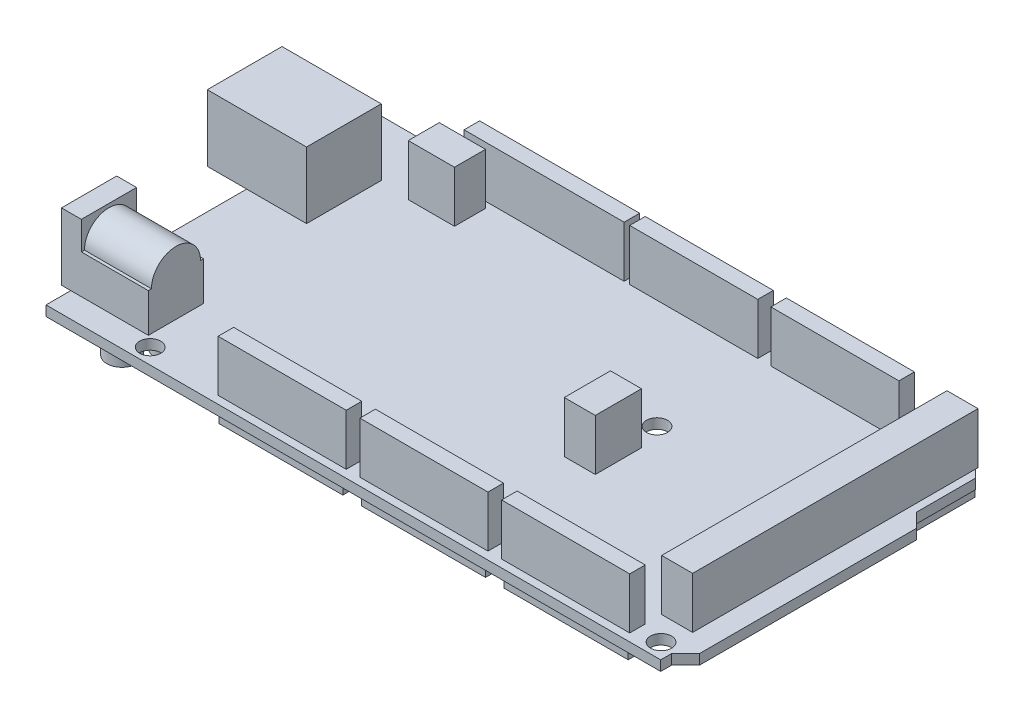
from build123d import *

# Parameters (mm, degrees)
SKETCH2_R           = 1.7
BOSS_EXTRUDE1_DEPTH = 1.625
SKETCH3_W           = 16
SKETCH3_H           = 12.05
BOSS_EXTRUDE2_DEPTH = 10.7
SKETCH4_W           = 14
SKETCH4_H           = 8.9
BOSS_EXTRUDE3_DEPTH = 6.25
SKETCH5_W           = 3.2
SKETCH5_H           = 8.9
BOSS_EXTRUDE4_DEPTH = 4.55
SKETCH6_R           = 3.95
BOSS_EXTRUDE5_DEPTH = 10.8
SKETCH7_R           = 2.43
SKETCH7_R_2         = 1.75
SKETCH7_W           = 4.5
SKETCH7_H           = 45
SKETCH7_W_2         = 20
SKETCH7_H_2         = 2.75
SKETCH7_W_3         = 24.5
SKETCH7_W_4         = 4.25
SKETCH7_H_3         = 7
BOSS_EXTRUDE6_DEPTH = 2.5
SKETCH8_W           = 25.8
SKETCH8_H           = 2.5
SKETCH8_W_2         = 20.65
SKETCH8_W_3         = 5
SKETCH8_H_2         = 46
SKETCH8_H_3         = 7.45
SKETCH8_W_4         = 7.45
SKETCH8_H_4         = 5
BOSS_EXTRUDE7_DEPTH = 8.25


with BuildPart() as part:
    # Sketch2 → Boss-Extrude1 (new body)
    with BuildSketch(Plane(origin=(0, 0, 0), x_dir=(1, 0, 0), z_dir=(0, 1, 0))):
        Polygon((99.1, 0), (99.1, 1.75), (101.35, 4), (101.35, 39), (99.1, 41.25), (99.1, 50.75), (96.45, 53.4), (0, 53.4), (0, 0), align=None)
        with Locations((96.65, 2.5)):
            Circle(SKETCH2_R, mode=Mode.SUBTRACT)
        with Locations((90.65, 50.95)):
            Circle(SKETCH2_R, mode=Mode.SUBTRACT)
        with Locations((15.45, 50.95)):
            Circle(SKETCH2_R, mode=Mode.SUBTRACT)
        with Locations((14.3, 2.5)):
            Circle(SKETCH2_R, mode=Mode.SUBTRACT)
        with Locations((66.2, 32.3)):
            Circle(SKETCH2_R, mode=Mode.SUBTRACT)
        with Locations((66.2, 7.7)):
            Circle(SKETCH2_R, mode=Mode.SUBTRACT)
    extrude(amount=BOSS_EXTRUDE1_DEPTH)

    # Sketch3 → Boss-Extrude2 (add)
    with BuildSketch(Plane(origin=(0, 1.625, 0), x_dir=(1, 0, 0), z_dir=(0, 1, 0))):
        with Locations((1.65, 38.375)):
            Rectangle(SKETCH3_W, SKETCH3_H)
    extrude(amount=BOSS_EXTRUDE2_DEPTH)

    # Sketch4 → Boss-Extrude3 (add)
    with BuildSketch(Plane(origin=(0, 1.625, 0), x_dir=(1, 0, 0), z_dir=(0, 1, 0))):
        with Locations((5.5, 8.45)):
            Rectangle(SKETCH4_W, SKETCH4_H)
    extrude(amount=BOSS_EXTRUDE3_DEPTH)

    # Sketch5 → Boss-Extrude4 (add)
    with BuildSketch(Plane(origin=(0, 7.875, 0), x_dir=(1, 0, 0), z_dir=(0, 1, 0))):
        with Locations((0.1, 8.45)):
            Rectangle(SKETCH5_W, SKETCH5_H)
    extrude(amount=BOSS_EXTRUDE4_DEPTH)

    # Sketch6 → Boss-Extrude5 (add)
    with BuildSketch(Plane(origin=(1.7, 0, 0), x_dir=(0, 0, -1), z_dir=(1, 0, 0))):
        with Locations((8.45, 7.875)):
            Circle(SKETCH6_R)
    extrude(amount=BOSS_EXTRUDE5_DEPTH)

    # Sketch7 → Boss-Extrude6 (add)
    with BuildSketch(Plane.XZ):
        with Locations((9, -3.25)):
            Circle(SKETCH7_R)
        with Locations((6, -8)):
            Circle(SKETCH7_R)
        with Locations((12, -8)):
            Circle(SKETCH7_R)
        with Locations((4, -32.65)):
            Circle(SKETCH7_R_2)
        with Locations((4, -44.65)):
            Circle(SKETCH7_R_2)
        with Locations((95.35, -29.65)):
            Rectangle(SKETCH7_W, SKETCH7_H)
        with Locations((77.6, -51.025)):
            Rectangle(SKETCH7_W_2, SKETCH7_H_2)
        with Locations((54.6, -51.025)):
            Rectangle(SKETCH7_W_2, SKETCH7_H_2)
        with Locations((30.35, -51.025)):
            Rectangle(SKETCH7_W_3, SKETCH7_H_2)
        with Locations((82.35, -2.875)):
            Rectangle(SKETCH7_W_2, SKETCH7_H_2)
        with Locations((59.35, -2.875)):
            Rectangle(SKETCH7_W_2, SKETCH7_H_2)
        with Locations((36.35, -2.875)):
            Rectangle(SKETCH7_W_2, SKETCH7_H_2)
        with Locations((64.075, -24.8)):
            Rectangle(SKETCH7_W_4, SKETCH7_H_3)
    extrude(amount=BOSS_EXTRUDE6_DEPTH)

    # Sketch8 → Boss-Extrude7 (add)
    with BuildSketch(Plane(origin=(0, 1.625, 0), x_dir=(1, 0, 0), z_dir=(0, 1, 0))):
        with Locations((30.4, 51.15)):
            Rectangle(SKETCH8_W, SKETCH8_H)
        with Locations((54.525, 51.15)):
            Rectangle(SKETCH8_W_2, SKETCH8_H)
        with Locations((77.275, 51.15)):
            Rectangle(SKETCH8_W_2, SKETCH8_H)
        with Locations((95.35, 29.4)):
            Rectangle(SKETCH8_W_3, SKETCH8_H_2)
        with Locations((36.825, 2.5)):
            Rectangle(SKETCH8_W_2, SKETCH8_H)
        with Locations((59.675, 2.5)):
            Rectangle(SKETCH8_W_2, SKETCH8_H)
        with Locations((82.525, 2.5)):
            Rectangle(SKETCH8_W_2, SKETCH8_H)
        with Locations((65.45, 24.325)):
            Rectangle(SKETCH8_W_3, SKETCH8_H_3)
        with Locations((18.225, 46.4)):
            Rectangle(SKETCH8_W_4, SKETCH8_H_4)
    extrude(amount=BOSS_EXTRUDE7_DEPTH)


solid = part.part
